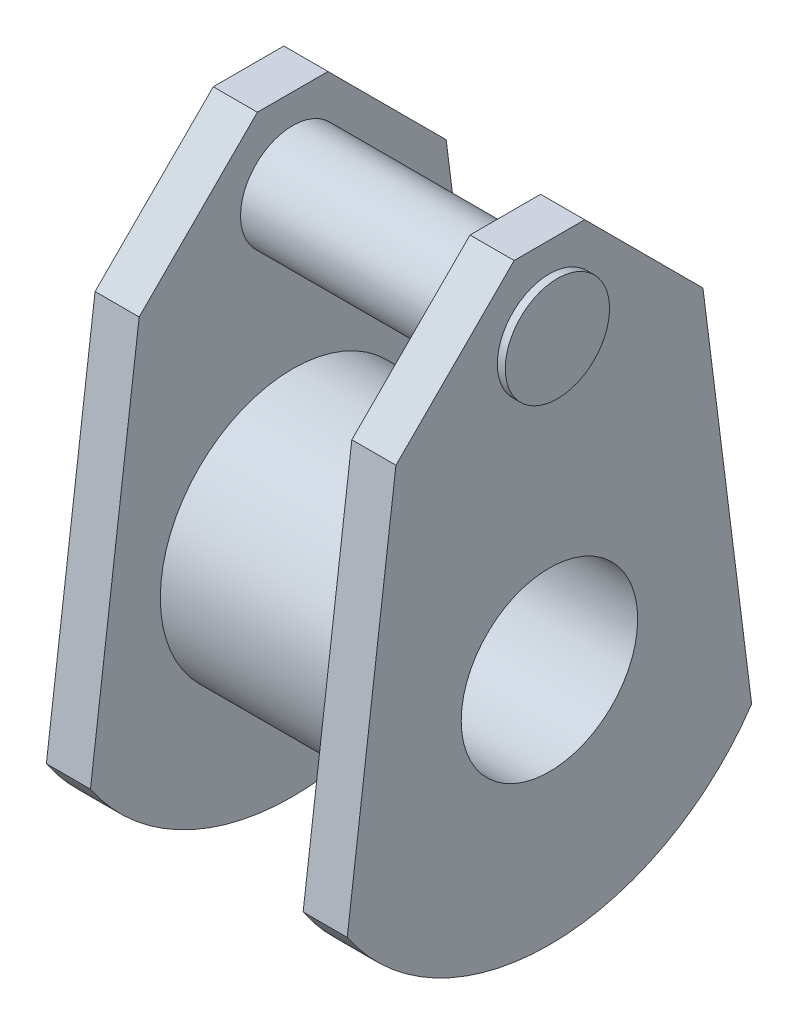
from build123d import *

# Parameters (mm, degrees)
IZIM2_R                          = 15
IZIM2_R_2                        = 10
Y_KSEKLIK_EKSTR_ZYON1_DEPTH      = 12.05
IZIM3_R                          = 10
Y_KSEKLIK_EKSTR_ZYON2_DEPTH      = 5
IZIM4_R                          = 15
Y_KSEKLIK_EKSTR_ZYON3_DEPTH      = 5
IZIM7_R                          = 15
IZIM7_R_2                        = 10
Y_KSEKLIK_EKSTR_ZYON4_DEPTH      = 5
IZIM5_R                          = 5.907014981
Y_KSEKLIK_EKSTR_ZYON5_DEPTH      = 1
Y_KSEKLIK_EKSTR_ZYON5_DEPTH_BACK = 35


with BuildPart() as part:
    # Çizim2 → Yükseklik-Ekstrüzyon1 (new body, symmetric)
    with BuildSketch(Plane(origin=(0, 0, 0), x_dir=(0, 0, -1), z_dir=(1, 0, 0))):
        Circle(IZIM2_R)
        Circle(IZIM2_R_2, mode=Mode.SUBTRACT)
    extrude(amount=Y_KSEKLIK_EKSTR_ZYON1_DEPTH, both=True)

    # Çizim3 → Yükseklik-Ekstrüzyon2 (add)
    with BuildSketch(Plane(origin=(12.05, 0, 0), x_dir=(0, 0, -1), z_dir=(1, 0, 0))):
        with BuildLine():
            Line((-4, 42.176870951), (4, 42.176870951))
            Line((4, 42.176870951), (17.395555059, 28.781315891))
            Line((17.395555059, 28.781315891), (22.914530919, -14.80525669))
            ThreePointArc((22.914530919, -14.80525669), (0, -26.990652818), (-22.914530919, -14.80525669))
            Line((-22.914530919, -14.80525669), (-17.395555059, 28.781315891))
            Line((-17.395555059, 28.781315891), (-4, 42.176870951))
        make_face()
        Circle(IZIM3_R, mode=Mode.SUBTRACT)
    extrude(amount=Y_KSEKLIK_EKSTR_ZYON2_DEPTH)



with BuildPart() as body_2:
    # Çizim4 → Yükseklik-Ekstrüzyon3 (new body)
    with BuildSketch(Plane.ZY.offset(12.05)):
        with BuildLine():
            Line((-4, 42.176870951), (4, 42.176870951))
            Line((4, 42.176870951), (17.395555059, 28.781315891))
            Line((17.395555059, 28.781315891), (22.914530919, -14.80525669))
            ThreePointArc((22.914530919, -14.80525669), (0, -26.990652818), (-22.914530919, -14.80525669))
            Line((-22.914530919, -14.80525669), (-17.395555059, 28.781315891))
            Line((-17.395555059, 28.781315891), (-4, 42.176870951))
        make_face()
        Circle(IZIM4_R, mode=Mode.SUBTRACT)
    extrude(amount=Y_KSEKLIK_EKSTR_ZYON3_DEPTH)


with BuildPart() as part_1:
    add(part.part)

    add(body_2.part)  # Yükseklik-Ekstrüzyon4 merges body 2
    # Çizim7 → Yükseklik-Ekstrüzyon4 (add)
    with BuildSketch(Plane.ZY.offset(12.05)):
        Circle(IZIM7_R)
        Circle(IZIM7_R_2, mode=Mode.SUBTRACT)
    extrude(amount=Y_KSEKLIK_EKSTR_ZYON4_DEPTH)

    # Çizim5 → Yükseklik-Ekstrüzyon5 (add, two sides)
    with BuildSketch(Plane.ZY.offset(17.05)) as y_kseklik_ekstr_zyon5_sk:
        with Locations((0, 32.957419359)):
            Circle(IZIM5_R)
    extrude(amount=Y_KSEKLIK_EKSTR_ZYON5_DEPTH)
    extrude(y_kseklik_ekstr_zyon5_sk.sketch, amount=-Y_KSEKLIK_EKSTR_ZYON5_DEPTH_BACK)


solid = part_1.part
